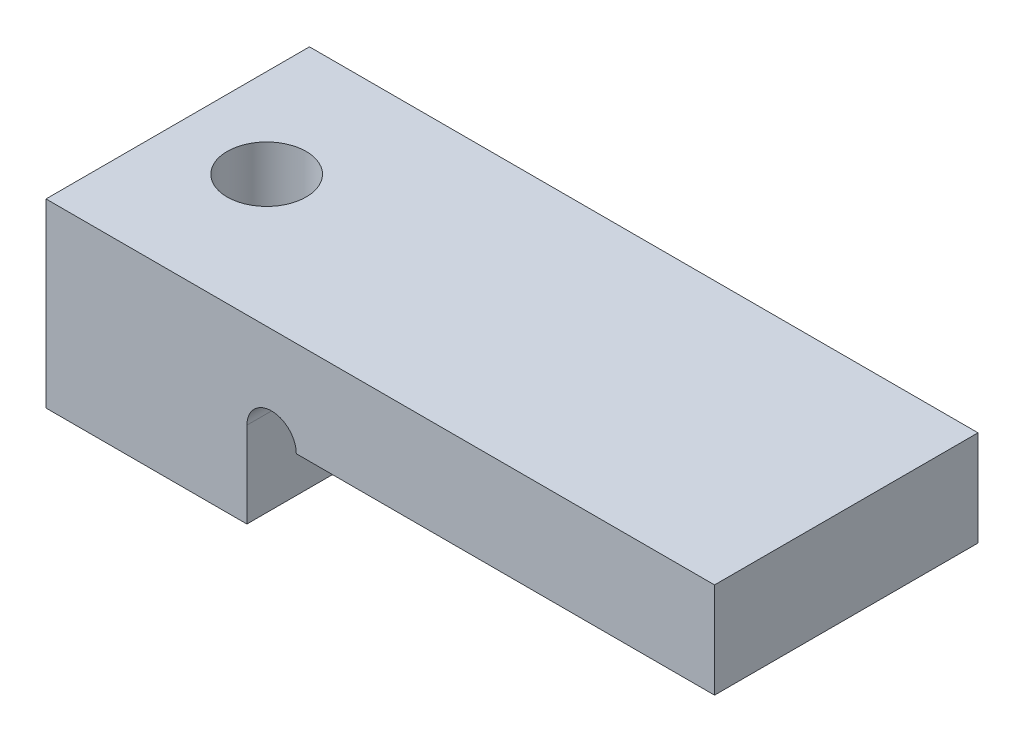
from build123d import *

# Parameters (mm, degrees)
BOSS_EXTRUDE2_DEPTH     = 4
SKETCH2_R               = 1.2
CUT_EXTRUDE2_DEPTH      = 6.5
CUT_EXTRUDE2_DEPTH_BACK = 1
SKETCH3_R               = 0.75
CUT_EXTRUDE3_DEPTH      = 5
CUT_EXTRUDE3_DEPTH_BACK = 5


with BuildPart() as part:
    # Sketch1 → Boss-Extrude2 (new body, symmetric)
    with BuildSketch(Plane.XY):
        Polygon((0, 0), (6.1, 0), (6.1, 2.6), (20.3, 2.6), (20.3, 5.5), (0, 5.5), align=None)
    extrude(amount=BOSS_EXTRUDE2_DEPTH, both=True)

    # Sketch2 → Cut-Extrude2 (cut, two sides)
    with BuildSketch(Plane(origin=(0, 0, 0), x_dir=(1, 0, 0), z_dir=(0, 1, 0))) as cut_extrude2_sk:
        with Locations((2.7, 0)):
            Circle(SKETCH2_R)
    extrude(amount=CUT_EXTRUDE2_DEPTH, mode=Mode.SUBTRACT)
    extrude(cut_extrude2_sk.sketch, amount=-CUT_EXTRUDE2_DEPTH_BACK, mode=Mode.SUBTRACT)

    # Sketch3 → Cut-Extrude3 (cut, two sides)
    with BuildSketch(Plane.XY) as cut_extrude3_sk:
        with Locations((6.85, 2.6)):
            Circle(SKETCH3_R)
    extrude(amount=CUT_EXTRUDE3_DEPTH, mode=Mode.SUBTRACT)
    extrude(cut_extrude3_sk.sketch, amount=-CUT_EXTRUDE3_DEPTH_BACK, mode=Mode.SUBTRACT)


solid = part.part
